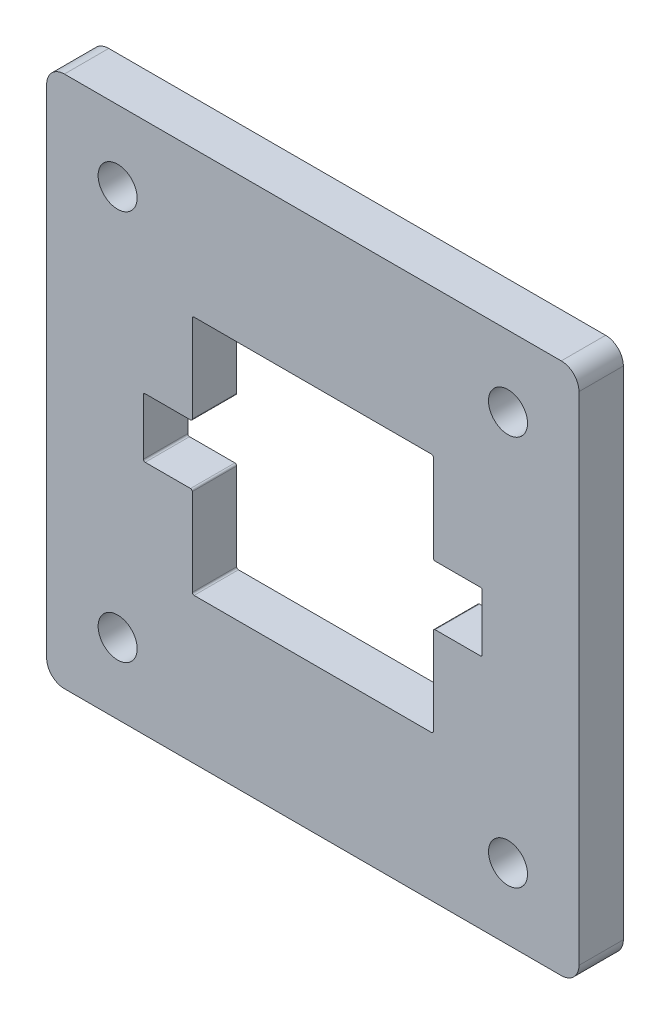
from build123d import *

# Parameters (mm, degrees)
SKETCH1_W             = 38.1
SKETCH1_H             = 38.1
BOSS_EXTRUDE1_DEPTH   = 3.175
FILLET1_R             = 1.27
FILLET2_R             = 0.127
F_3_CLEARANCE_HOLE1_D = 2.794


with BuildPart() as part:
    # Sketch1 → Boss-Extrude1 (new body)
    with BuildSketch(Plane.XY):
        with Locations((19.05, 19.05)):
            Rectangle(SKETCH1_W, SKETCH1_H)
        Polygon((10.425, 10.425), (10.425, 16.925), (6.925, 16.925), (6.925, 21.175), (10.425, 21.175), (10.425, 27.675), (27.675, 27.675), (27.675, 21.175), (31.175, 21.175), (31.175, 16.925), (27.675, 16.925), (27.675, 10.425), align=None, mode=Mode.SUBTRACT)
    extrude(amount=BOSS_EXTRUDE1_DEPTH)

    # Fillet1
    fillet1_edges = [part.edges().sort_by_distance(p)[0] for p in [
        (0, 38.1, 1.5875),
        (38.1, 38.1, 1.5875),
        (38.1, 0, 1.5875),
        (0, 0, 1.5875),
    ]]
    fillet(fillet1_edges, radius=FILLET1_R)

    # Fillet2
    fillet2_edges = [part.edges().sort_by_distance(p)[0] for p in [
        (10.425, 10.425, 1.5875),
        (27.675, 10.425, 1.5875),
        (27.675, 16.925, 1.5875),
        (31.175, 16.925, 1.5875),
        (31.175, 21.175, 1.5875),
        (27.675, 21.175, 1.5875),
        (27.675, 27.675, 1.5875),
        (10.425, 27.675, 1.5875),
        (10.425, 21.175, 1.5875),
        (6.925, 21.175, 1.5875),
        (6.925, 16.925, 1.5875),
        (10.425, 16.925, 1.5875),
    ]]
    fillet(fillet2_edges, radius=FILLET2_R)

    # #3 Clearance Hole1 (through all)
    with Locations(Plane.XY.offset(3.175)):
        with Locations((5.08, 33.02), (33.02, 33.02), (33.02, 5.08), (5.08, 5.08)):
            Hole(F_3_CLEARANCE_HOLE1_D / 2)


solid = part.part
